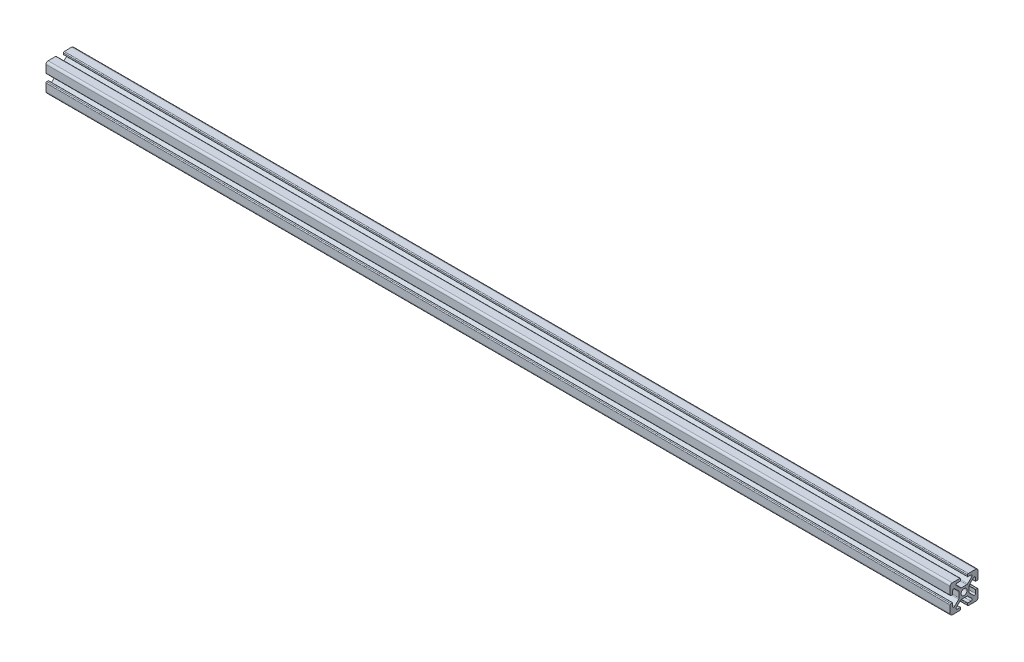
from build123d import *

# Parameters (mm, degrees)
BOSS_EXTRUDE1_DEPTH = 650


with BuildPart() as part:
    # Sketch3 → Boss-Extrude1 (new body)
    with BuildSketch(Plane(origin=(0, 0, 0), x_dir=(0, 0, -1), z_dir=(1, 0, 0))):
        with BuildLine():
            Line((-5.515685425, 6.807463915), (-2.601114729, 3.892893219))
            ThreePointArc((-2.601114729, 3.892893219), (-2.27669138, 3.676120467), (-1.894007948, 3.6))
            Line((-1.894007948, 3.6), (0, 3.6))
            Line((0, 3.6), (0, 2.15))
            ThreePointArc((0, 2.15), (-1.52027958, 1.52027958), (-2.15, 0))
            Line((-2.15, 0), (-3.6, 0))
            Line((-3.6, 0), (-3.6, 1.894007948))
            ThreePointArc((-3.6, 1.894007948), (-3.676120467, 2.27669138), (-3.892893219, 2.601114729))
            Line((-3.892893219, 2.601114729), (-6.807463915, 5.515685425))
            ThreePointArc((-6.807463915, 5.515685425), (-7.679296086, 5.689103626), (-8.17314934, 4.95))
            Line((-8.17314934, 4.95), (-8.17314934, 2.7))
            ThreePointArc((-8.17314934, 2.7), (-8.231727984, 2.558578644), (-8.37314934, 2.5))
            Line((-8.37314934, 2.5), (-9.4, 2.5))
            ThreePointArc((-9.4, 2.5), (-9.824264069, 2.675735931), (-10, 3.1))
            Line((-10, 3.1), (-10, 8.5))
            ThreePointArc((-10, 8.5), (-9.560660172, 9.560660172), (-8.5, 10))
            Line((-8.5, 10), (-3.1, 10))
            ThreePointArc((-3.1, 10), (-2.675735931, 9.824264069), (-2.5, 9.4))
            Line((-2.5, 9.4), (-2.5, 8.37314934))
            ThreePointArc((-2.5, 8.37314934), (-2.558578644, 8.231727984), (-2.7, 8.17314934))
            Line((-2.7, 8.17314934), (-4.95, 8.17314934))
            ThreePointArc((-4.95, 8.17314934), (-5.689103626, 7.679296086), (-5.515685425, 6.807463915))
        make_face()
    extrude(amount=-BOSS_EXTRUDE1_DEPTH)

    # Mirror1: part across plane


with BuildPart() as part_1:
    add(part.part)
    add(part.part.mirror(Plane.ZX))

    # Mirror2: part across plane


with BuildPart() as part_2:
    add(part_1.part)
    add(part_1.part.mirror(Plane.XY))


solid = part_2.part
